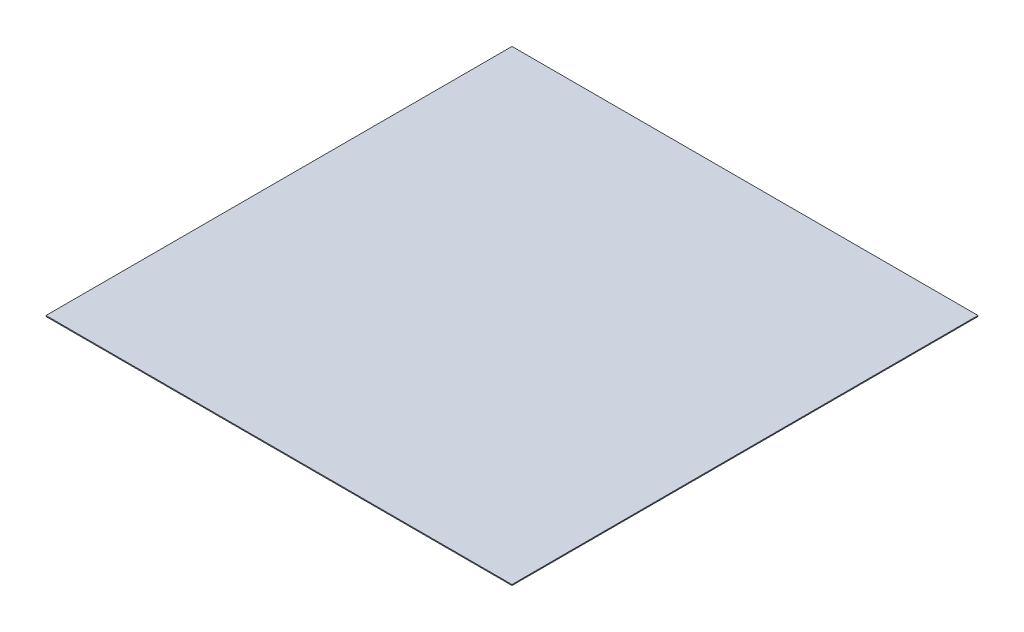
from build123d import *

# Parameters (mm, degrees)
SKETCH1_W           = 10000
SKETCH1_H           = 10000
BOSS_EXTRUDE1_DEPTH = 20


with BuildPart() as part:
    # Sketch1 → Boss-Extrude1 (new body)
    with BuildSketch(Plane(origin=(0, 0, 0), x_dir=(1, 0, 0), z_dir=(0, 1, 0))):
        Rectangle(SKETCH1_W, SKETCH1_H)
    extrude(amount=BOSS_EXTRUDE1_DEPTH)


solid = part.part
